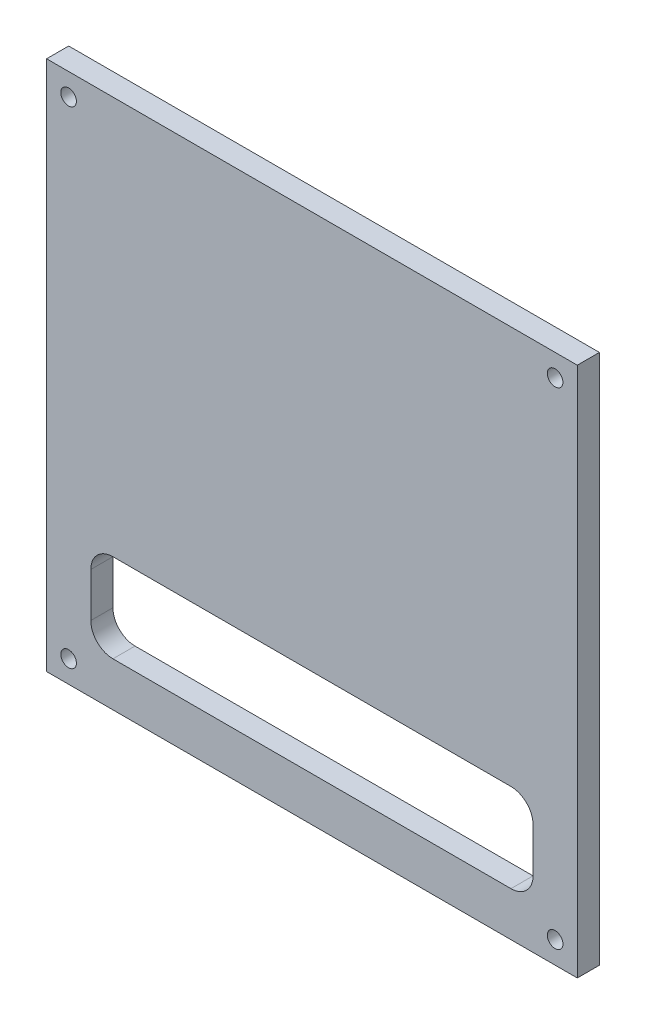
from build123d import *

# Parameters (mm, degrees)
SKETCH1_W             = 127
SKETCH1_H             = 25.4
BOSS_EXTRUDE1_DEPTH   = 6.35
F_8_CLEARANCE_HOLE2_D = 4.4958
LPATTERN1_COUNT       = 2
LPATTERN1_PITCH       = 139.7
LPATTERN1_COUNT_DIR2  = 2
LPATTERN1_PITCH_DIR2  = 139.7


with BuildPart() as part:
    # Sketch1 → Boss-Extrude1 (new body)
    with BuildSketch(Plane.XY):
        Polygon((-163.974683544, 121.551475626), (-163.974683544, 83.451475626), (-316.374683544, 83.451475626), (-316.374683544, 121.551475626), (-316.374683544, 235.851475626), (-163.974683544, 235.851475626), align=None)
        with Locations((-240.174683544, 108.851475626)):
            Rectangle(SKETCH1_W, SKETCH1_H, mode=Mode.SUBTRACT)
        with BuildLine():
            Line((-303.674683544, 121.551475626), (-303.674683544, 115.201475626))
            ThreePointArc((-303.674683544, 115.201475626), (-301.814811605, 119.691603686), (-297.324683544, 121.551475626))
            Line((-297.324683544, 121.551475626), (-303.674683544, 121.551475626))
        make_face()
        with BuildLine():
            Line((-303.674683544, 102.501475626), (-303.674683544, 96.151475626))
            Line((-303.674683544, 96.151475626), (-297.324683544, 96.151475626))
            ThreePointArc((-297.324683544, 96.151475626), (-301.814811605, 98.011347565), (-303.674683544, 102.501475626))
        make_face()
        with BuildLine():
            ThreePointArc((-183.024683544, 121.551475626), (-178.534555484, 119.691603686), (-176.674683544, 115.201475626))
            Line((-176.674683544, 115.201475626), (-176.674683544, 121.551475626))
            Line((-176.674683544, 121.551475626), (-183.024683544, 121.551475626))
        make_face()
        with BuildLine():
            ThreePointArc((-176.674683544, 102.501475626), (-178.534555484, 98.011347565), (-183.024683544, 96.151475626))
            Line((-183.024683544, 96.151475626), (-176.674683544, 96.151475626))
            Line((-176.674683544, 96.151475626), (-176.674683544, 102.501475626))
        make_face()
    extrude(amount=BOSS_EXTRUDE1_DEPTH)

    # #8 Clearance Hole2 (through all)
    with Locations(Plane.XY.offset(6.35)):
        with Locations((-310.051516204, 229.517938536)):
            f_8_clearance_hole2 = Hole(F_8_CLEARANCE_HOLE2_D / 2)

    # LPattern1: 8 Clearance Hole2 2 × 2
    with Locations(*[(j * LPATTERN1_PITCH_DIR2, -i * LPATTERN1_PITCH, 0) for i in range(LPATTERN1_COUNT) for j in range(LPATTERN1_COUNT_DIR2) if (i, j) != (0, 0)]):
        add(f_8_clearance_hole2, mode=Mode.SUBTRACT)


solid = part.part
